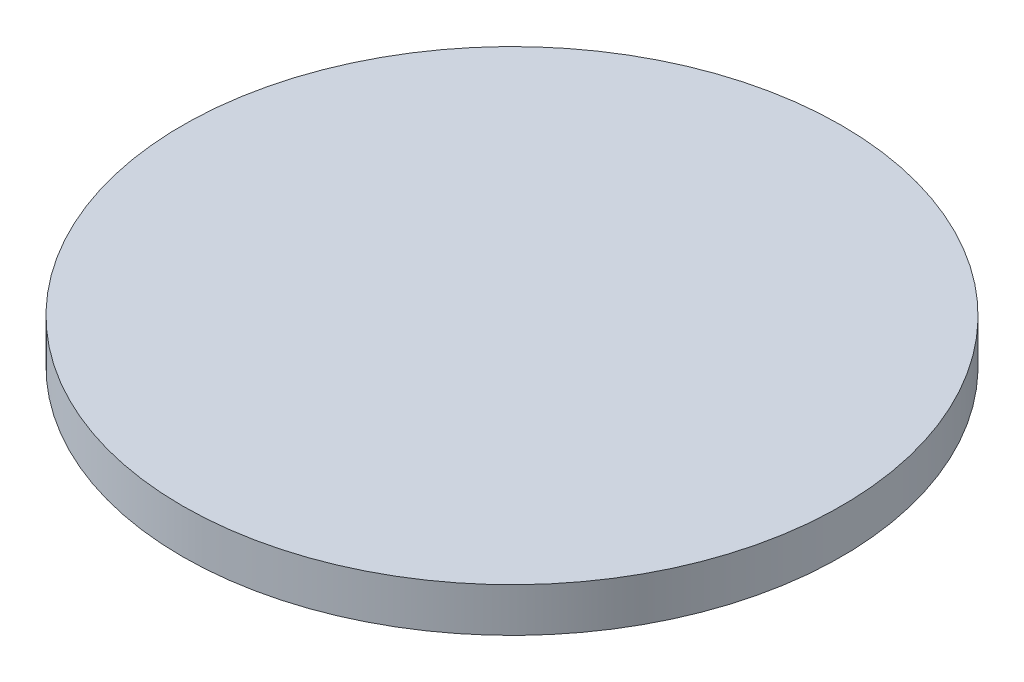
from build123d import *

# Parameters (mm, degrees)
ESQUISSE1_R        = 22.5
BOSS_EXTRU_1_DEPTH = 1.5


with BuildPart() as part:
    # Esquisse1 → Boss.-Extru.1 (new body, symmetric)
    with BuildSketch(Plane(origin=(0, 0, 0), x_dir=(1, 0, 0), z_dir=(0, 1, 0))):
        Circle(ESQUISSE1_R)
    extrude(amount=BOSS_EXTRU_1_DEPTH, both=True)


solid = part.part
